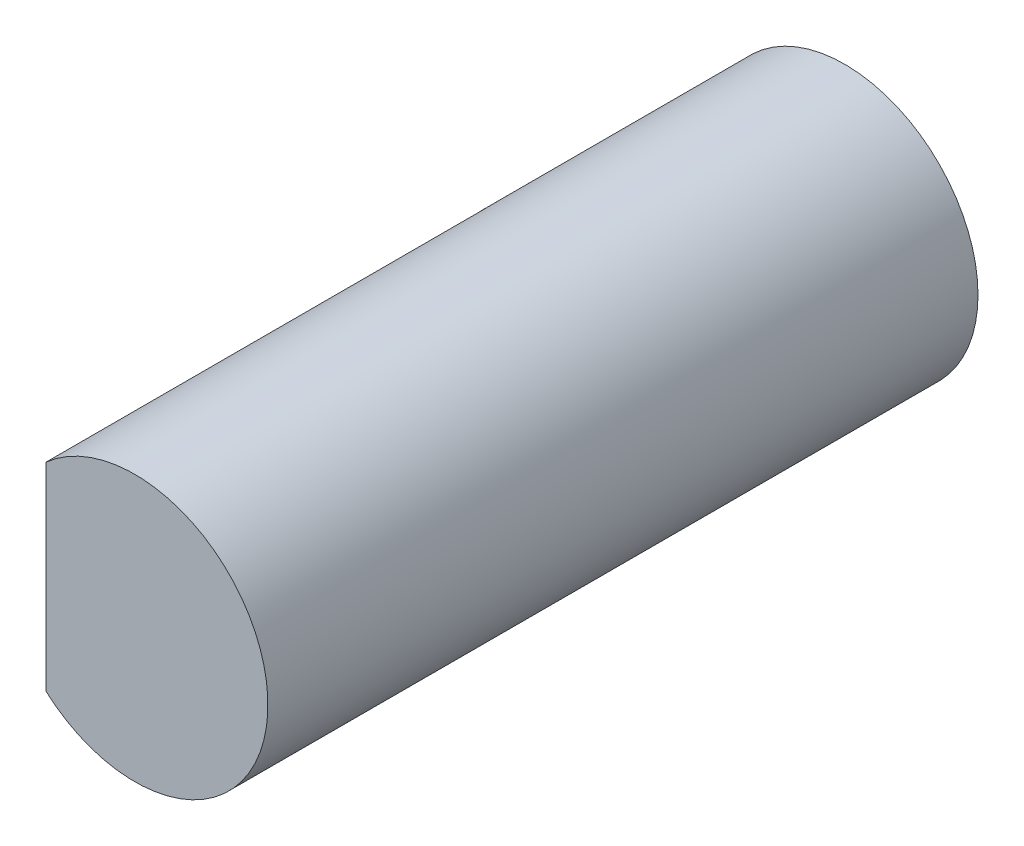
from build123d import *

# Parameters (mm, degrees)
SKETCH1_R           = 1.5
BOSS_EXTRUDE1_DEPTH = 8
SKETCH2_W           = 0.6
SKETCH2_H           = 3
CUT_EXTRUDE1_DEPTH  = 5


with BuildPart() as part:
    # Sketch1 → Boss-Extrude1 (new body)
    with BuildSketch(Plane.XY):
        Circle(SKETCH1_R)
    extrude(amount=BOSS_EXTRUDE1_DEPTH)

    # Sketch2 → Cut-Extrude1 (cut)
    with BuildSketch(Plane.XY.offset(8)):
        with Locations((-1.3, 0)):
            Rectangle(SKETCH2_W, SKETCH2_H)
    extrude(amount=-CUT_EXTRUDE1_DEPTH, mode=Mode.SUBTRACT)


solid = part.part
